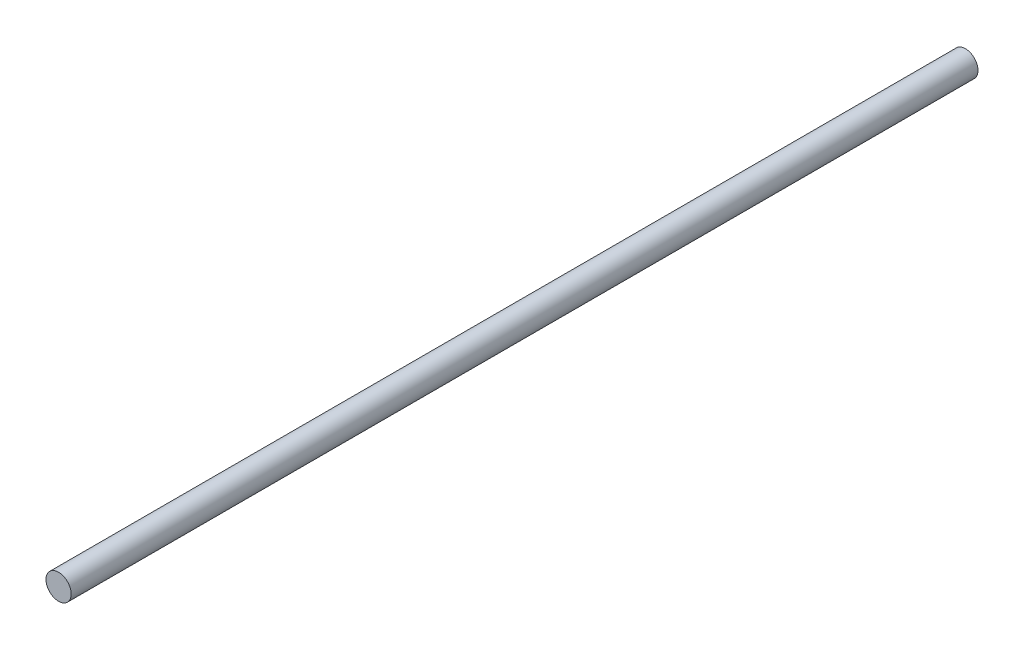
from build123d import *

# Parameters (mm, degrees)
SKETCH1_R           = 6.35
BOSS_EXTRUDE1_DEPTH = 457.2


with BuildPart() as part:
    # Sketch1 → Boss-Extrude1 (new body)
    with BuildSketch(Plane.XY):
        Circle(SKETCH1_R)
    extrude(amount=BOSS_EXTRUDE1_DEPTH)


solid = part.part
